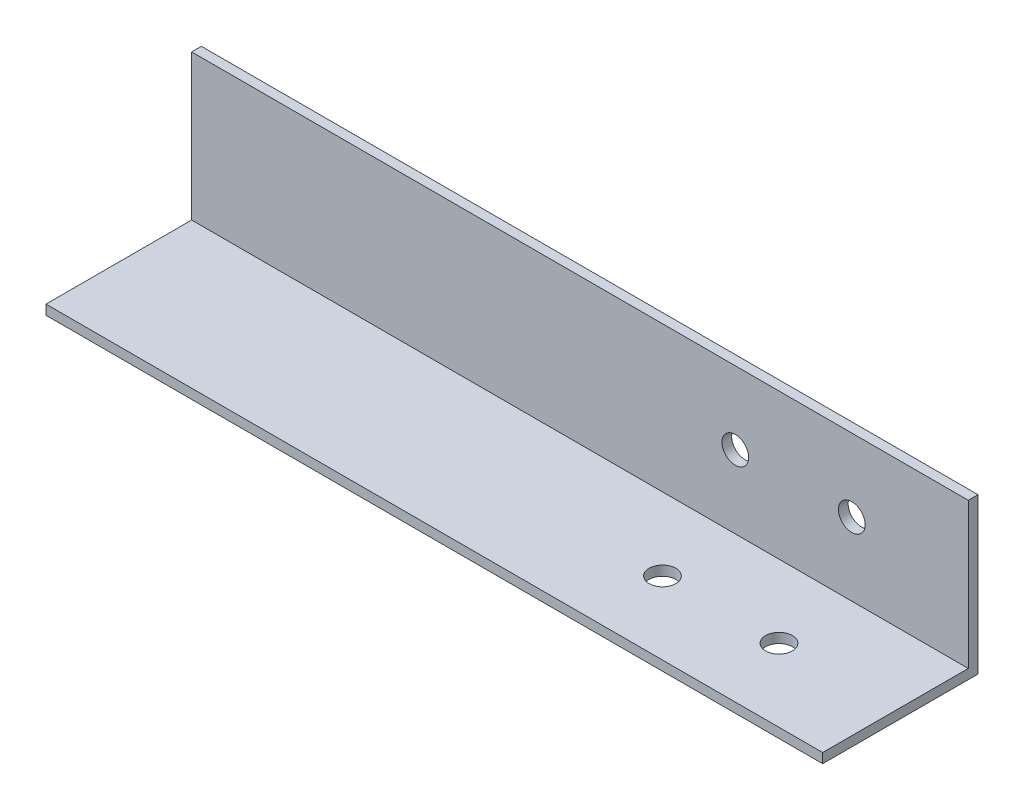
from build123d import *

# Parameters (mm, degrees)
BOSS_EXTRUDE1_DEPTH = 254
SKETCH2_R           = 4.365625
CUT_EXTRUDE1_DEPTH  = 3.175
SKETCH3_R           = 4.365625
CUT_EXTRUDE2_DEPTH  = 3.175


with BuildPart() as part:
    # Sketch1 → Boss-Extrude1 (new body)
    with BuildSketch(Plane(origin=(0, 0, 0), x_dir=(0, 0, -1), z_dir=(1, 0, 0))):
        Polygon((-3.175, 0), (-50.8, 0), (-50.8, -3.175), (0, -3.175), (0, 0), (0, 47.625), (-3.175, 47.625), align=None)
    extrude(amount=BOSS_EXTRUDE1_DEPTH)

    # Sketch2 → Cut-Extrude1 (cut)
    with BuildSketch(Plane.XY.offset(3.175)):
        with Locations((177.8, 23.8125)):
            Circle(SKETCH2_R)
        with Locations((215.9, 23.8125)):
            Circle(SKETCH2_R)
    extrude(amount=-CUT_EXTRUDE1_DEPTH, mode=Mode.SUBTRACT)

    # Sketch3 → Cut-Extrude2 (cut)
    with BuildSketch(Plane(origin=(0, 0, 0), x_dir=(1, 0, 0), z_dir=(0, 1, 0))):
        with Locations((177.8, -26.9875)):
            Circle(SKETCH3_R)
        with Locations((215.9, -26.9875)):
            Circle(SKETCH3_R)
    extrude(amount=-CUT_EXTRUDE2_DEPTH, mode=Mode.SUBTRACT)


solid = part.part
